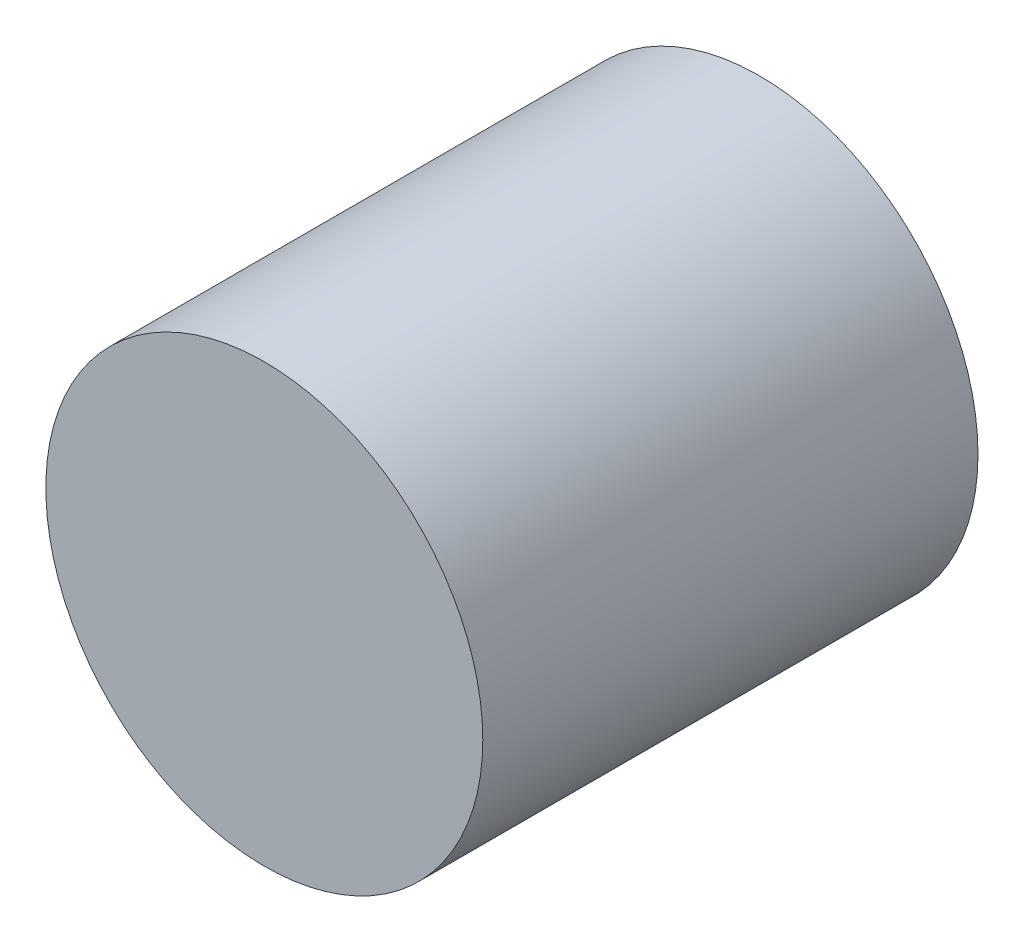
from build123d import *

# Parameters (mm, degrees)
SKETCH1_R           = 75
BOSS_EXTRUDE1_DEPTH = 170


with BuildPart() as part:
    # Sketch1 → Boss-Extrude1 (new body)
    with BuildSketch(Plane.XY):
        Circle(SKETCH1_R)
    extrude(amount=BOSS_EXTRUDE1_DEPTH)


solid = part.part
